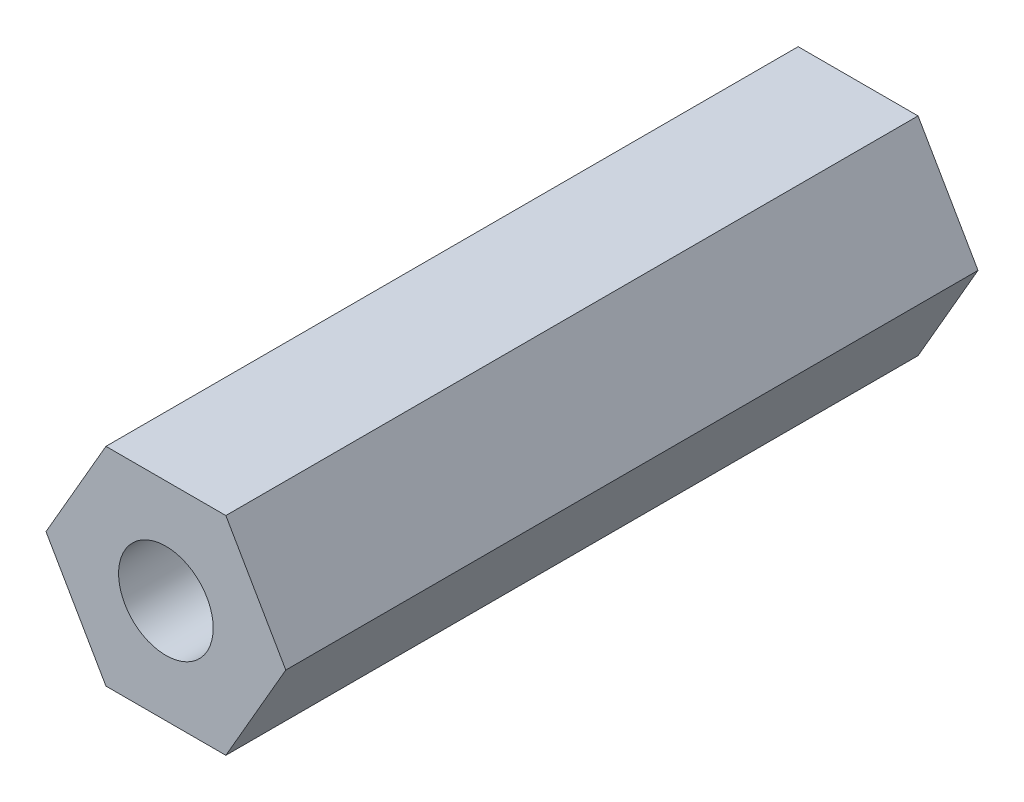
from build123d import *

# Parameters (mm, degrees)
BOSS_EXTRUDE1_DEPTH           = 15
TAP_DRILL_FOR_M2_5_TAP1_D     = 2.05
TAP_DRILL_FOR_M2_5_TAP1_DEPTH = 11.5


with BuildPart() as part:
    # Sketch1 → Boss-Extrude1 (new body)
    with BuildSketch(Plane.XY):
        Polygon((-1.299038106, 2.25), (-2.598076211, 0), (-1.299038106, -2.25), (1.299038106, -2.25), (2.598076211, 0), (1.299038106, 2.25), align=None)
    extrude(amount=BOSS_EXTRUDE1_DEPTH)

    # Tap Drill for M2.5 Tap1
    with Locations(Plane.XY.offset(15)):
        with Locations((0, 0)):
            Hole(TAP_DRILL_FOR_M2_5_TAP1_D / 2, depth=TAP_DRILL_FOR_M2_5_TAP1_DEPTH)


solid = part.part
